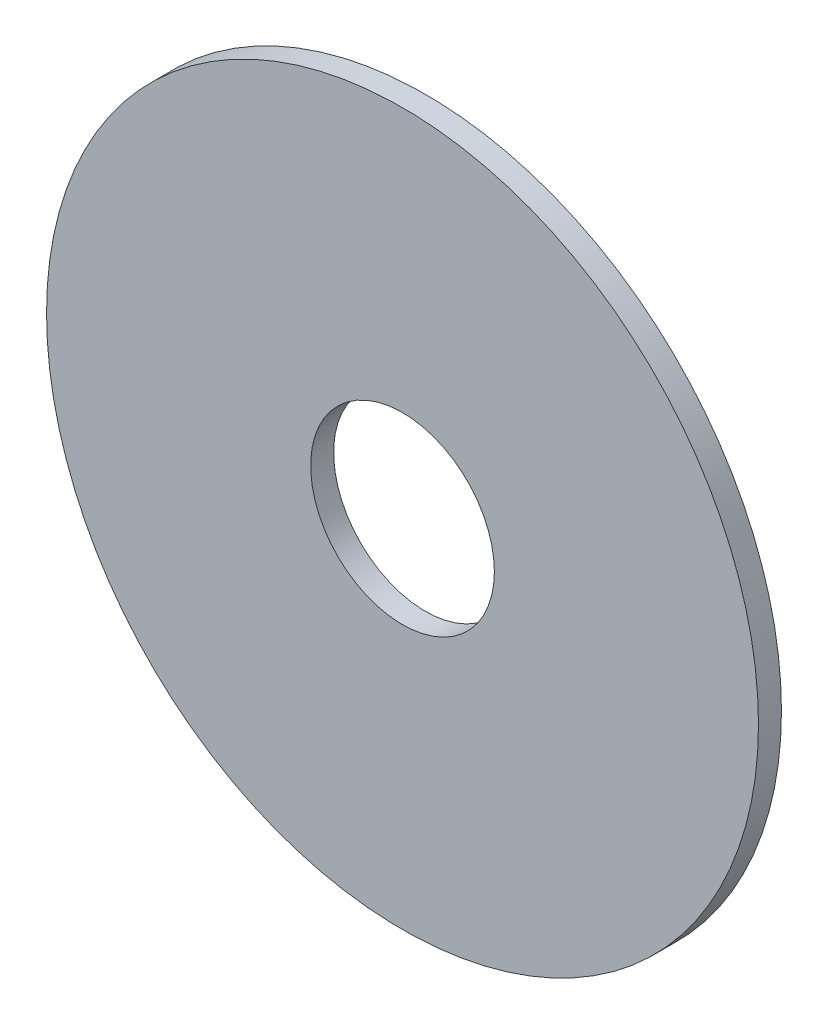
from build123d import *

# Parameters (mm, degrees)
CROQUIS1_R              = 3.875
CROQUIS1_R_2            = 1
SALIENTE_EXTRUIR1_DEPTH = 0.25


with BuildPart() as part:
    # Croquis1 → Saliente-Extruir1 (new body)
    with BuildSketch(Plane.XY):
        Circle(CROQUIS1_R)
        Circle(CROQUIS1_R_2, mode=Mode.SUBTRACT)
    extrude(amount=SALIENTE_EXTRUIR1_DEPTH)


solid = part.part
